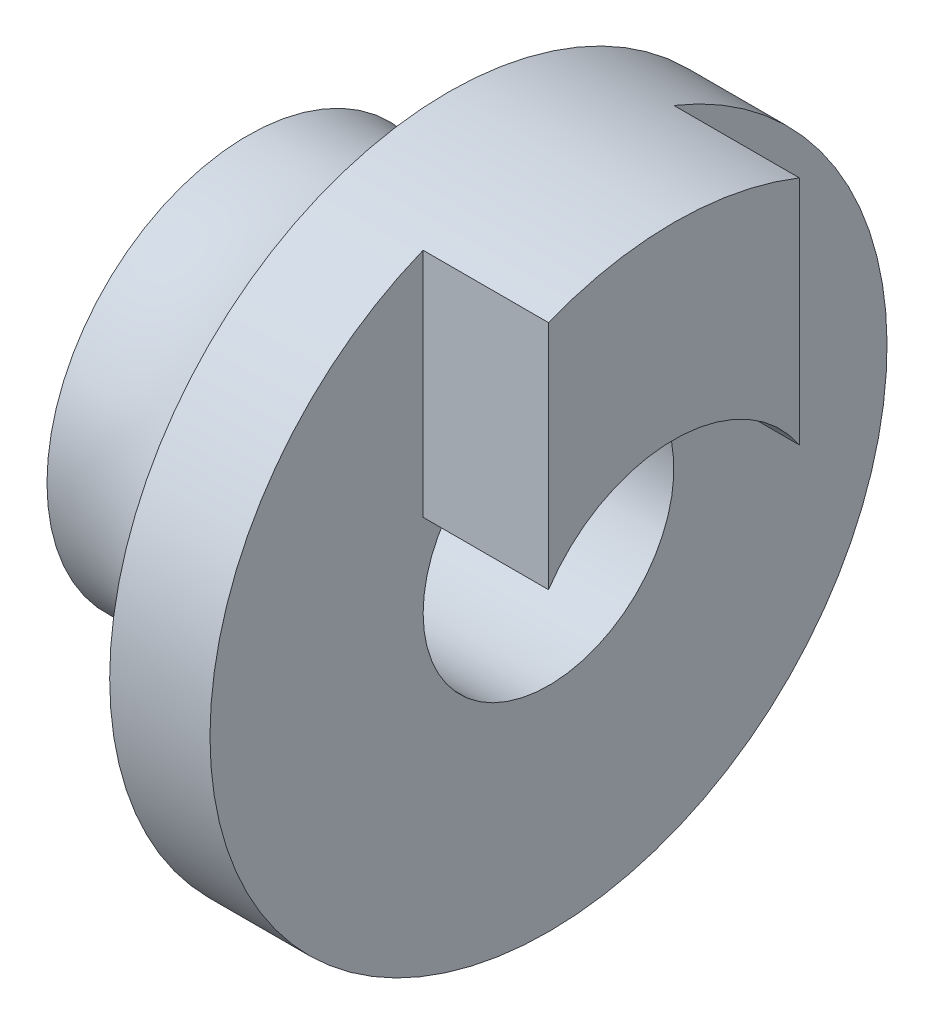
from build123d import *

# Parameters (mm, degrees)
EXTRUSION1_DEPTH = 5


with BuildPart() as part:
    # Esquisse1 → Révolution1 (revolve)
    with BuildSketch(Plane.XY, mode=Mode.PRIVATE) as r_volution1_sk:
        with BuildLine():
            Line((-12, 5), (-12, 8))
            ThreePointArc((-12, 8), (-8.192021355, 8.387659794), (-5, 10.5))
            Line((-5, 10.5), (-4, 10.5))
            Line((-4, 10.5), (-4, 13.5))
            Line((-4, 13.5), (0, 13.5))
            Line((0, 13.5), (0, 5))
            Line((0, 5), (-12, 5))
        make_face()
    revolve(r_volution1_sk.sketch.rotate(Axis((-16.08577031, 0, 0), (1, 0, 0)), 90), axis=Axis((-16.08577031, 0, 0), (1, 0, 0)))  # turned: the seam where the file's is

    # Esquisse2 → Extrusion1 (add)
    with BuildSketch(Plane(origin=(0, 0, 0), x_dir=(0, 0, -1), z_dir=(1, 0, 0))):
        with BuildLine():
            Line((-5, 12.539936204), (-5, 3.31662479))
            ThreePointArc((-5, 3.31662479), (0, 6), (5, 3.31662479))
            Line((5, 3.31662479), (5, 12.539936204))
            ThreePointArc((5, 12.539936204), (0, 13.5), (-5, 12.539936204))
        make_face()
    extrude(amount=EXTRUSION1_DEPTH)


solid = part.part
